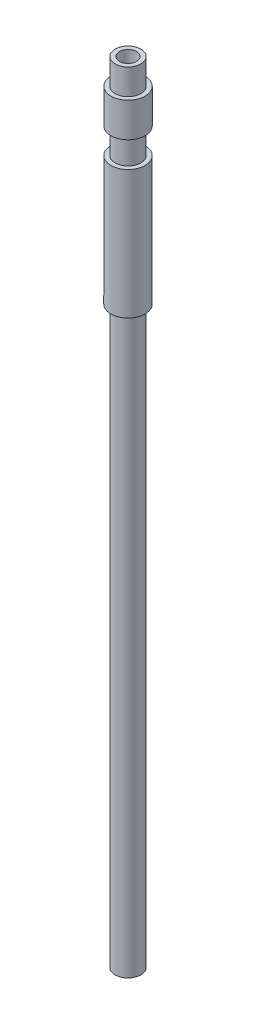
from build123d import *

# Parameters (mm, degrees)
SKETCH_1_R      = 2
SKETCH_1_R_2    = 1
EXTRUDE_1_DEPTH = 92
SKETCH_2_W      = 0.5
SKETCH_2_H      = 3
SKETCH_3_W      = 0.5
SKETCH_3_H      = 67


with BuildPart() as part:
    # Эскиз1 → Бобышка-Вытянуть1 (new body)
    with BuildSketch(Plane(origin=(0, 0, 0), x_dir=(1, 0, 0), z_dir=(0, 1, 0))):
        Circle(SKETCH_1_R)
        Circle(SKETCH_1_R_2, mode=Mode.SUBTRACT)
    extrude(amount=EXTRUDE_1_DEPTH)

    # Эскиз2 → Вырез-Повернуть1 (revolve, cut)
    with BuildSketch(Plane.XY):
        with Locations((1.75, 90.5)):
            Rectangle(SKETCH_2_W, SKETCH_2_H)
        with Locations((1.75, 83.5)):
            Rectangle(SKETCH_2_W, SKETCH_2_H)
    revolve(axis=Axis((0, 92, 0), (0, -1, 0)), mode=Mode.SUBTRACT)

    # Эскиз3 → Вырез-Повернуть2 (revolve, cut)
    with BuildSketch(Plane.XY):
        with Locations((1.75, 33.5)):
            Rectangle(SKETCH_3_W, SKETCH_3_H)
    revolve(axis=Axis((0, 0, 0), (0, 1, 0)), mode=Mode.SUBTRACT)


solid = part.part
